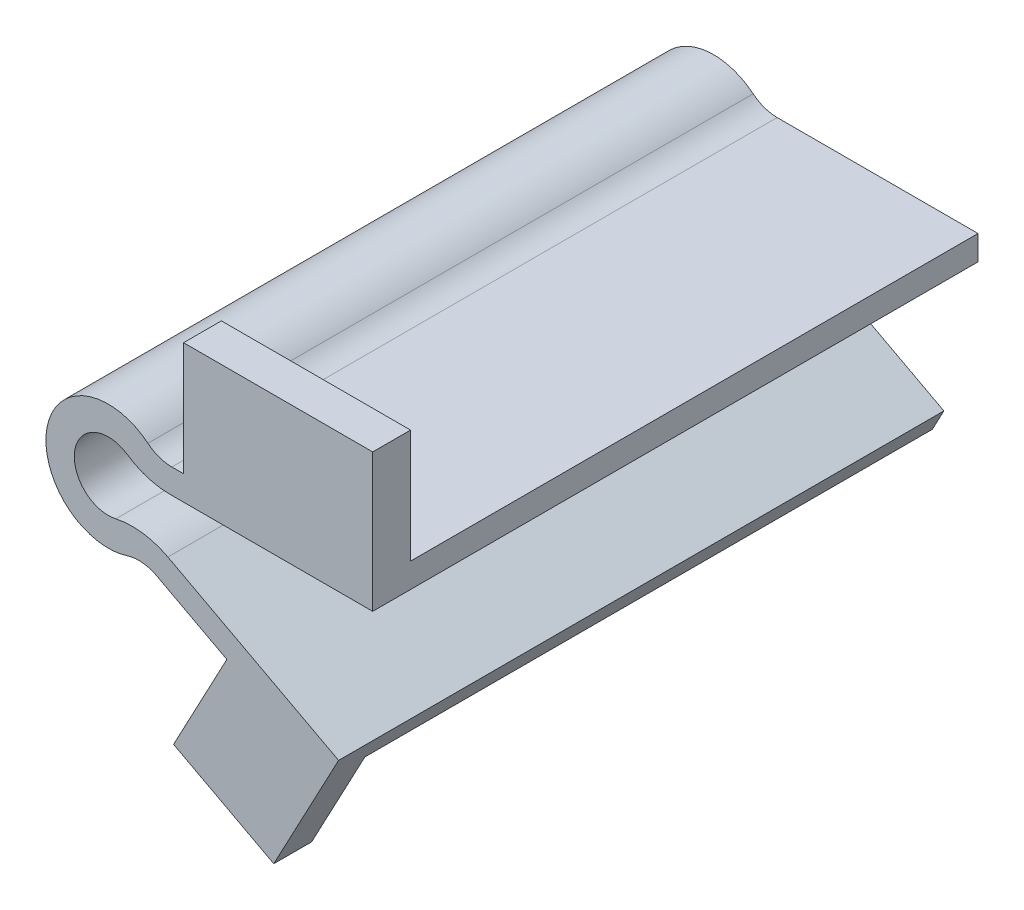
from build123d import *

# Parameters (mm, degrees)
BOSS_EXTRUDE2_DEPTH = 16
FILLET3_R           = 1
FILLET6_R           = 2
SKETCH7_W           = 5
SKETCH7_H           = 3
BOSS_EXTRUDE6_DEPTH = 1


with BuildPart() as part:
    # Sketch5 → Boss-Extrude2 (new body)
    with BuildSketch(Plane(origin=(4.228476288, 0, 0), x_dir=(1, 0, 0), z_dir=(0, 0, 1))):
        with BuildLine():
            Line((2.760085796, 0.4), (-3.422250513, 0.4))
            ThreePointArc((-3.422250513, 0.4), (-5.121328449, 0.113203437), (-3.547587232, -0.588549143))
            Line((-3.547587232, -0.588549143), (1.85826255, -3.462890458))
            Line((1.85826255, -3.462890458), (1.553106034, -4.036806393))
            Line((1.553106034, -4.036806393), (-3.378850655, -1.414438505))
            ThreePointArc((-3.378850655, -1.414438505), (-5.854676969, 0.279233492), (-2.955684082, 1.05))
            Line((-2.955684082, 1.05), (2.760085796, 1.05))
            Line((2.760085796, 1.05), (2.760085796, 0.4))
        make_face()
    extrude(amount=BOSS_EXTRUDE2_DEPTH)

    # Fillet3
    fillet3_edges = [part.edges().sort_by_distance(p)[0] for p in [
        (0.849625632, -1.414438505, 8),
        (1.272792206, 1.05, 8),
    ]]
    fillet(fillet3_edges, radius=FILLET3_R)

    # Fillet6
    fillet6_edges = [part.edges().sort_by_distance(p)[0] for p in [
        (0.680889056, -0.588549143, 8),
        (0.806225775, 0.4, 8),
    ]]
    fillet(fillet6_edges, radius=FILLET6_R)

    # Sketch7 → Boss-Extrude6 (add)
    with BuildSketch(Plane.XY.offset(16)):
        with Locations((4.488562084, 2.55)):
            Rectangle(SKETCH7_W, SKETCH7_H)
        Polygon((5.781582322, -4.036806393), (4.373167633, -6.685649172), (1.724324855, -5.277234484), (3.132739543, -2.628391705), align=None)
    extrude(amount=-BOSS_EXTRUDE6_DEPTH)


solid = part.part
